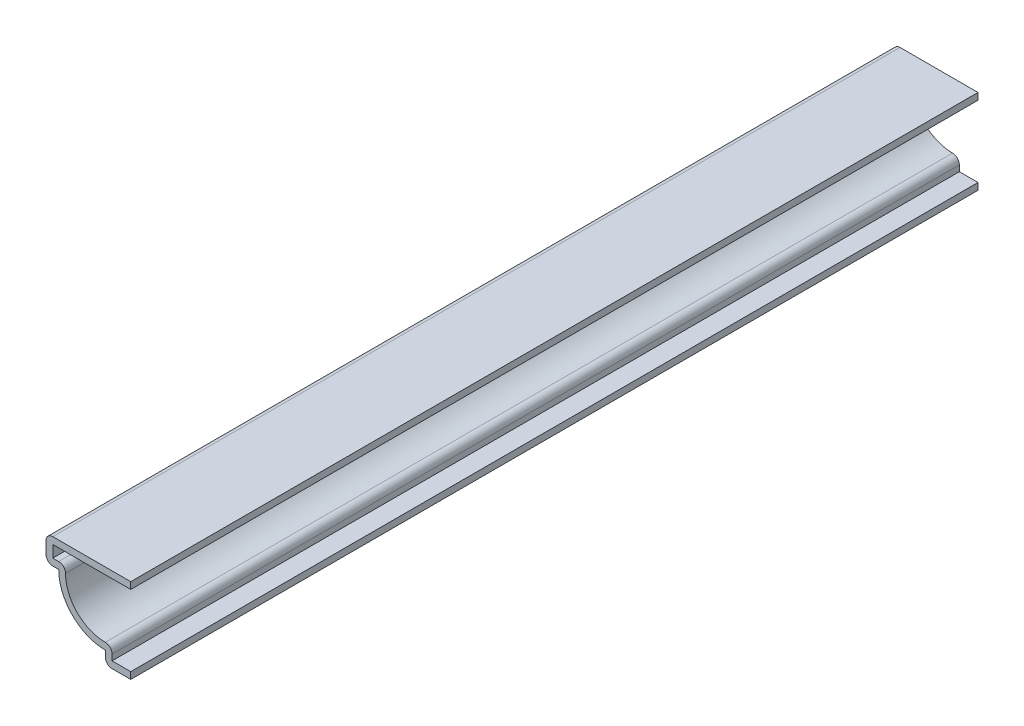
from build123d import *

# Parameters (mm, degrees)
EXTRUDE_THIN1_DEPTH = 158.75
FILLET1_R           = 1.27


with BuildPart() as part:
    # Sketch1 → Extrude-Thin1 (new body)
    with BuildSketch(Plane.XY):
        with BuildLine():
            Line((0, 0), (-4.7625, 0))
            Line((-4.7625, 0), (-4.7625, 2.38125))
            ThreePointArc((-4.7625, 2.38125), (-10.936426, 4.938574), (-13.49375, 11.1125))
            Line((-13.49375, 11.1125), (-15.875, 11.1125))
            Line((-15.875, 11.1125), (-15.875, 15.875))
            Line((-15.875, 15.875), (0, 15.875))
            Line((0, 15.875), (0, 14.605))
            Line((0, 14.605), (-14.605, 14.605))
            Line((-14.605, 14.605), (-14.605, 12.3825))
            Line((-14.605, 12.3825), (-12.11487, 12.3825))
            ThreePointArc((-12.11487, 12.3825), (-10.0384, 5.8366), (-3.4925, 3.76013))
            Line((-3.4925, 3.76013), (-3.4925, 1.27))
            Line((-3.4925, 1.27), (0, 1.27))
            Line((0, 1.27), (0, 0))
        make_face()
    extrude(amount=-EXTRUDE_THIN1_DEPTH)

    # Fillet1
    fillet1_edges = [part.edges().sort_by_distance(p)[0] for p in [
        (-12.11487, 12.3825, -79.375),
        (-3.4925, 3.76013, -79.375),
        (-4.7625, 0, -79.375),
        (-15.875, 11.1125, -79.375),
        (-15.875, 15.875, -79.375),
    ]]
    fillet(fillet1_edges, radius=FILLET1_R)


solid = part.part
